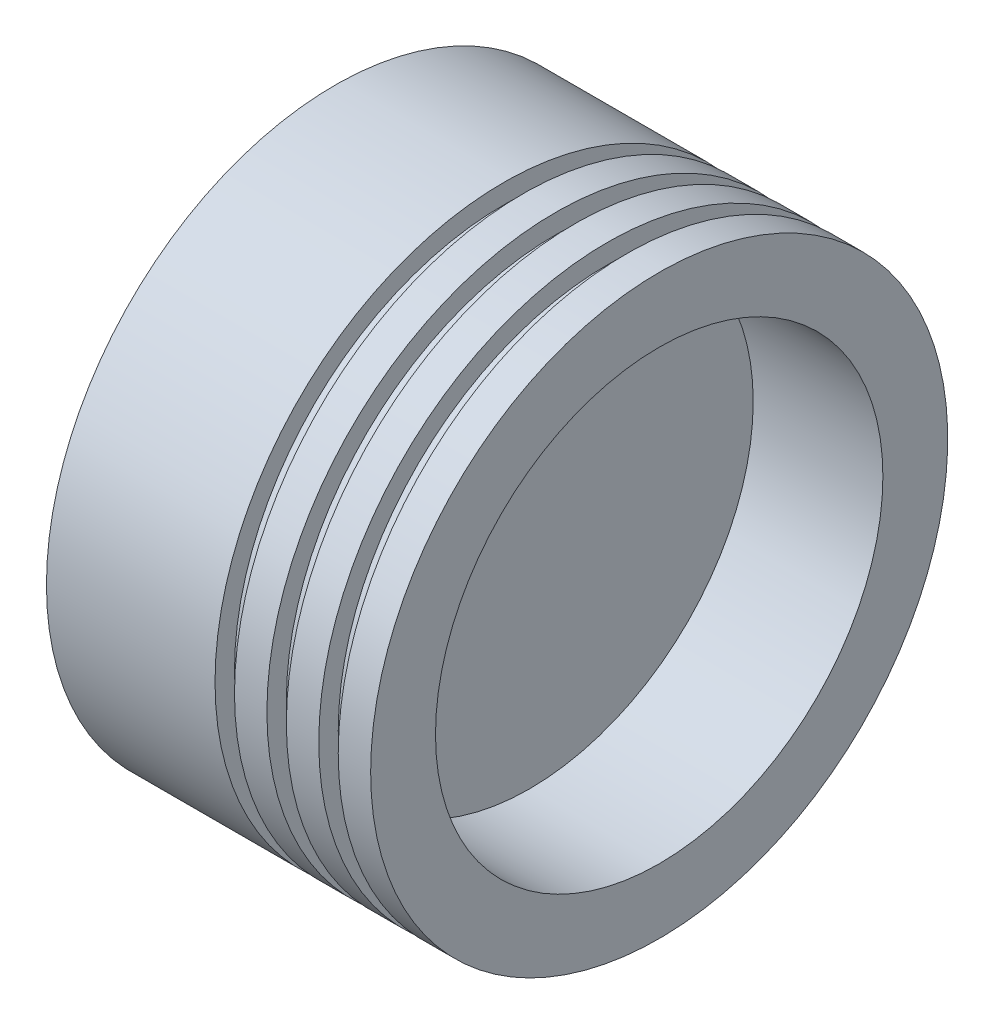
from build123d import *


with BuildPart() as part:
    # Sketch1 → Revolve1 (revolve)
    with BuildSketch(Plane.XY):
        Polygon((0, 0), (0, 44.5), (26, 44.5), (26, 41.5), (29, 41.5), (29, 44.5), (34, 44.5), (34, 41.5), (37, 41.5), (37, 44.5), (42, 44.5), (42, 41.5), (45, 41.5), (45, 44.5), (50, 44.5), (50, 34.5), (30, 34.5), (30, 0), align=None)
    revolve(axis=Axis((0, 0, 0), (1, 0, 0)))


solid = part.part
